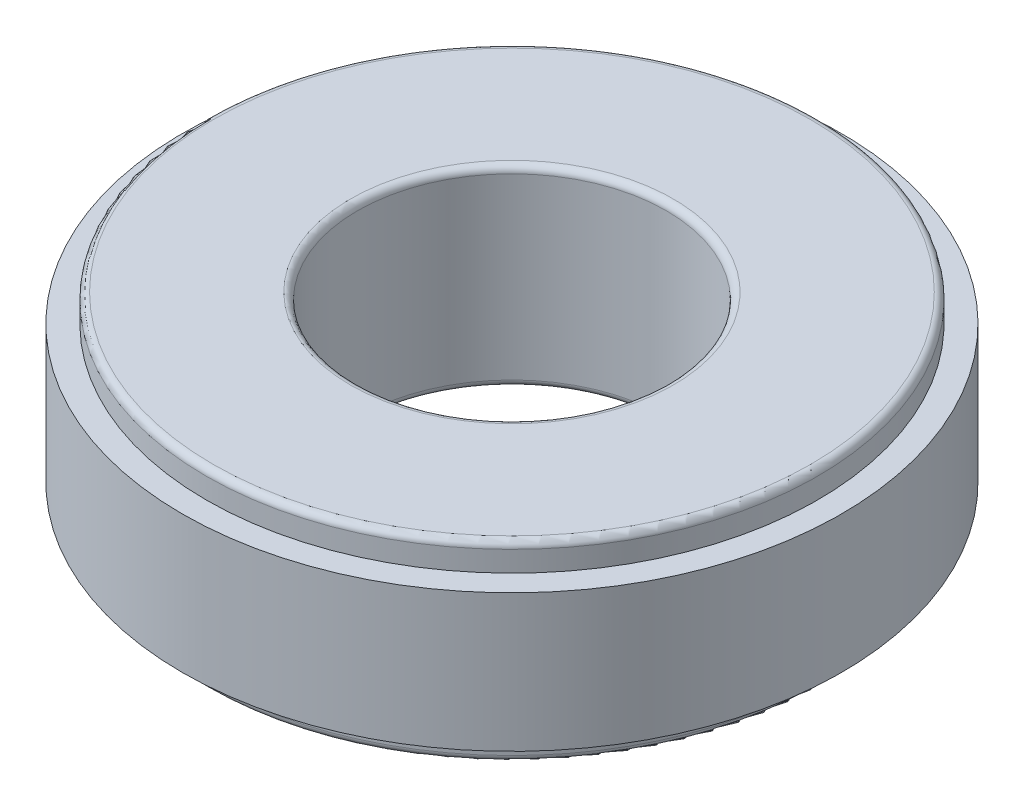
from build123d import *

# Parameters (mm, degrees)
SKETCH1_R           = 28.2575
STEP_DEPTH          = 2.54
SKETCH2_R           = 30.48
BODY_DEPTH          = 12.7
SKETCH3_R           = 28.2575
BOSS_EXTRUDE3_DEPTH = 2.54
SKETCH4_R           = 14.2875
CUT_EXTRUDE1_DEPTH  = 18.78
FILLET1_R           = 0.635


with BuildPart() as part:
    # Sketch1 → Step (new body)
    with BuildSketch(Plane(origin=(0, 0, 0), x_dir=(1, 0, 0), z_dir=(0, 1, 0))):
        Circle(SKETCH1_R)
    extrude(amount=STEP_DEPTH)

    # Sketch2 → Body (add)
    with BuildSketch(Plane(origin=(0, 2.54, 0), x_dir=(1, 0, 0), z_dir=(0, 1, 0))):
        Circle(SKETCH2_R)
    extrude(amount=BODY_DEPTH)

    # Sketch3 → Boss-Extrude3 (add)
    with BuildSketch(Plane(origin=(0, 15.24, 0), x_dir=(1, 0, 0), z_dir=(0, 1, 0))):
        Circle(SKETCH3_R)
    extrude(amount=BOSS_EXTRUDE3_DEPTH)

    # Sketch4 → Cut-Extrude1 (cut, through all)
    with BuildSketch(Plane(origin=(0, 17.78, 0), x_dir=(1, 0, 0), z_dir=(0, 1, 0))):
        Circle(SKETCH4_R)
    extrude(amount=-CUT_EXTRUDE1_DEPTH, mode=Mode.SUBTRACT)

    # Fillet1
    fillet1_edges = [part.edges().sort_by_distance(p)[0] for p in [
        (-28.2575, 17.78, 0),
        (-14.2875, 0, 0),
        (-14.2875, 17.78, 0),
        (-28.2575, 0, 0),
    ]]
    fillet(fillet1_edges, radius=FILLET1_R)


solid = part.part
